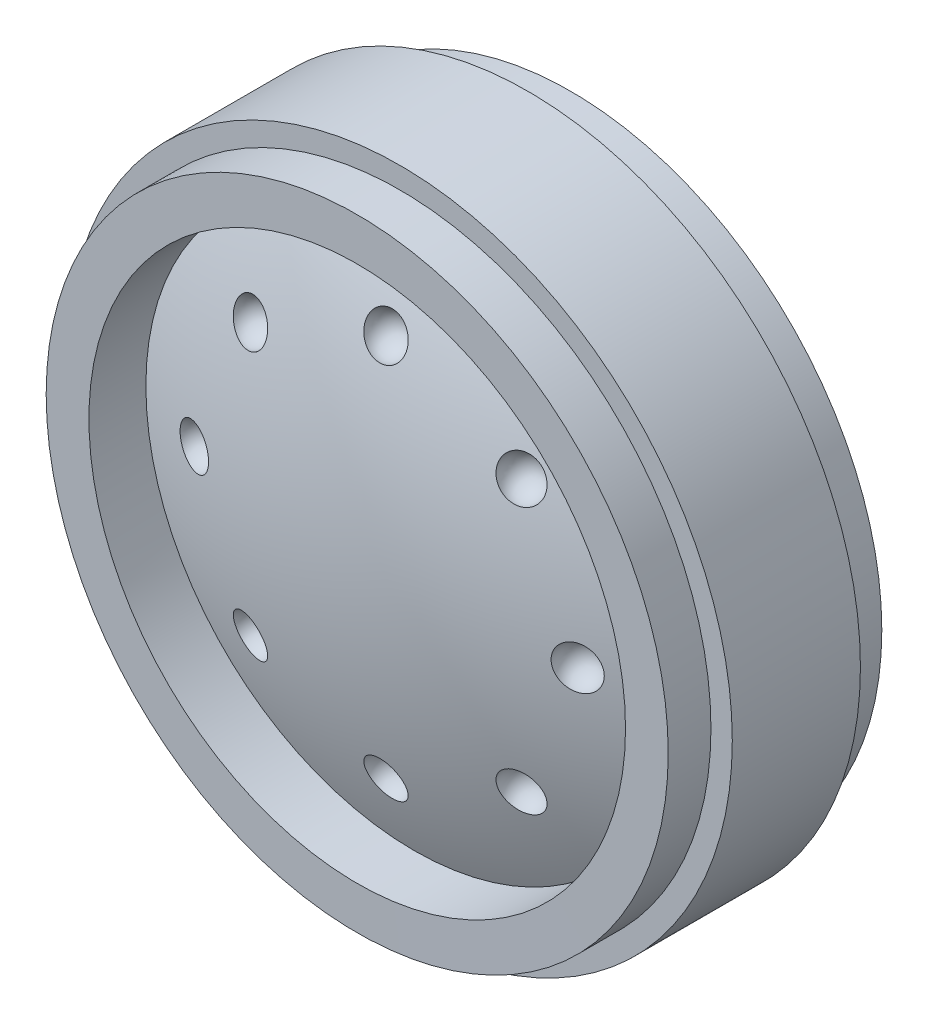
from build123d import *

# Parameters (mm, degrees)
CIRPATTERN1_COUNT = 8


with BuildPart() as part:
    # Sketch1 → Revolve1 (revolve)
    with BuildSketch(Plane(origin=(0, 0, 0), x_dir=(0, 0, -1), z_dir=(1, 0, 0)), mode=Mode.PRIVATE) as revolve1_sk:
        with BuildLine():
            Line((-6.049010000000001, 0), (-0.0012699999999996, 0))
            Line((-0.0012699999999996, 0), (-0.00127000000000026, 3.230391731973082))
            Line((-0.00127000000000026, 3.230391731973082), (5.909310000000001, 3.230391731973083))
            ThreePointArc((5.909310000000001, 3.230391731973083), (4.8637927323391, 9.343190762652467), (2.823033018409908, 15.19936))
            Line((2.823033018409908, 15.19936), (6.049010000000001, 15.19936))
            Line((6.049010000000001, 15.19936), (6.05028, 17.61998))
            Line((6.05028, 17.61998), (3.62966, 17.61998))
            Line((3.62966, 17.61998), (3.62966, 18.82902))
            Line((3.62966, 18.82902), (-3.62966, 18.82902))
            Line((-3.62966, 18.82902), (-3.62966, 17.61998))
            Line((-3.62966, 17.61998), (-6.05028, 17.61998))
            Line((-6.05028, 17.61998), (-6.049010000000001, 15.19936))
            Line((-6.049010000000001, 15.19936), (-2.823033018409908, 15.19936))
            ThreePointArc((-2.823033018409908, 15.19936), (-5.233632083583423, 7.768968269586206), (-6.049010000000001, 0))
        make_face()
    revolve(revolve1_sk.sketch.rotate(Axis((0, 0, 6.049010000000001), (0, 0, -1)), 90), axis=Axis((0, 0, 6.049010000000001), (0, 0, -1)))

    # Sketch2 → Cut-Revolve1 (revolve, cut)
    with BuildSketch(Plane.XY.offset(4.43611)):
        with BuildLine():
            Line((-1.209040000000002, 10.86358), (1.2090399999999986, 10.86358))
            ThreePointArc((1.2090399999999986, 10.86358), (-1.66e-15, 12.07262), (-1.209040000000002, 10.86358))
        make_face()
    cut_revolve1 = revolve(axis=Axis((-1.209040000000002, 10.86358, 4.43611), (1, 0, 0)), mode=Mode.SUBTRACT)

    # CirPattern1: Cut-Revolve1 ×8 about axis
    cirpattern1_axis = Axis((-9.52e-15, 2e-17, 0), (0, 0, 1))
    for i in range(1, CIRPATTERN1_COUNT):
        add(cut_revolve1.rotate(cirpattern1_axis, i * 360 / CIRPATTERN1_COUNT), mode=Mode.SUBTRACT)

    # Mirror1: Cut-Revolve1 across plane
    add(cut_revolve1.mirror(Plane.XY), mode=Mode.SUBTRACT)

    # Mirror1 copy 1 sketch → Mirror1 copy 1 (revolve, cut)
    with BuildSketch(Plane(origin=(-2.78e-15, 6.74e-15, -4.43611), x_dir=(0.7071067811865476, 0.7071067811865475, 0), z_dir=(0, 0, -1))):
        with BuildLine():
            Line((-1.209040000000002, -10.86358), (1.2090399999999986, -10.86358))
            ThreePointArc((1.2090399999999986, -10.86358), (-1.66e-15, -12.07262), (-1.209040000000002, -10.86358))
        make_face()
    revolve(axis=Axis((-8.536631468688341, 6.826790703236778, -4.43611), (-0.7071067811865476, -0.7071067811865475, 0)), mode=Mode.SUBTRACT)

    # Mirror1 copy 2 sketch → Mirror1 copy 2 (revolve, cut)
    with BuildSketch(Plane.YX.offset(4.43611)):
        with BuildLine():
            Line((-1.209040000000002, -10.86358), (1.2090399999999986, -10.86358))
            ThreePointArc((1.2090399999999986, -10.86358), (-1.66e-15, -12.07262), (-1.209040000000002, -10.86358))
        make_face()
    revolve(axis=Axis((-10.86358000000001, -1.2090399999999917, -4.43611), (-6e-17, -1, 0)), mode=Mode.SUBTRACT)

    # Mirror1 copy 3 sketch → Mirror1 copy 3 (revolve, cut)
    with BuildSketch(Plane(origin=(-1.624e-14, 6.76e-15, -4.43611), x_dir=(-0.7071067811865475, 0.7071067811865476, 0), z_dir=(0, 0, -1))):
        with BuildLine():
            Line((-1.209040000000002, -10.86358), (1.2090399999999986, -10.86358))
            ThreePointArc((1.2090399999999986, -10.86358), (-1.66e-15, -12.07262), (-1.209040000000002, -10.86358))
        make_face()
    revolve(axis=Axis((-6.826790703236787, -8.53663146868833, -4.43611), (0.7071067811865475, -0.7071067811865476, 0)), mode=Mode.SUBTRACT)

    # Mirror1 copy 4 sketch → Mirror1 copy 4 (revolve, cut)
    with BuildSketch(Plane(origin=(-1.904e-14, 3e-17, -4.43611), x_dir=(-1, 1.2e-16, 0), z_dir=(0, 0, -1))):
        with BuildLine():
            Line((-1.209040000000002, -10.86358), (1.2090399999999986, -10.86358))
            ThreePointArc((1.2090399999999986, -10.86358), (-1.66e-15, -12.07262), (-1.209040000000002, -10.86358))
        make_face()
    revolve(axis=Axis((1.2090399999999815, -10.86358, -4.43611), (1, -1.2e-16, 0)), mode=Mode.SUBTRACT)

    # Mirror1 copy 5 sketch → Mirror1 copy 5 (revolve, cut)
    with BuildSketch(Plane(origin=(-1.626e-14, -6.71e-15, -4.43611), x_dir=(-0.7071067811865477, -0.7071067811865475, 0), z_dir=(0, 0, -1))):
        with BuildLine():
            Line((-1.209040000000002, -10.86358), (1.2090399999999986, -10.86358))
            ThreePointArc((1.2090399999999986, -10.86358), (-1.66e-15, -12.07262), (-1.209040000000002, -10.86358))
        make_face()
    revolve(axis=Axis((8.536631468688322, -6.826790703236779, -4.43611), (0.7071067811865477, 0.7071067811865475, 0)), mode=Mode.SUBTRACT)

    # Mirror1 copy 6 sketch → Mirror1 copy 6 (revolve, cut)
    with BuildSketch(Plane(origin=(-9.54e-15, -9.5e-15, -4.43611), x_dir=(-1.8e-16, -1, 0), z_dir=(0, 0, -1))):
        with BuildLine():
            Line((-1.209040000000002, -10.86358), (1.2090399999999986, -10.86358))
            ThreePointArc((1.2090399999999986, -10.86358), (-1.66e-15, -12.07262), (-1.209040000000002, -10.86358))
        make_face()
    revolve(axis=Axis((10.863579999999992, 1.2090399999999903, -4.43611), (1.8e-16, 1, 0)), mode=Mode.SUBTRACT)

    # Mirror1 copy 7 sketch → Mirror1 copy 7 (revolve, cut)
    with BuildSketch(Plane(origin=(-2.8e-15, -6.73e-15, -4.43611), x_dir=(0.7071067811865474, -0.7071067811865477, 0), z_dir=(0, 0, -1))):
        with BuildLine():
            Line((-1.209040000000002, -10.86358), (1.2090399999999986, -10.86358))
            ThreePointArc((1.2090399999999986, -10.86358), (-1.66e-15, -12.07262), (-1.209040000000002, -10.86358))
        make_face()
    revolve(axis=Axis((6.826790703236769, 8.53663146868833, -4.43611), (-0.7071067811865474, 0.7071067811865477, 0)), mode=Mode.SUBTRACT)


solid = part.part
